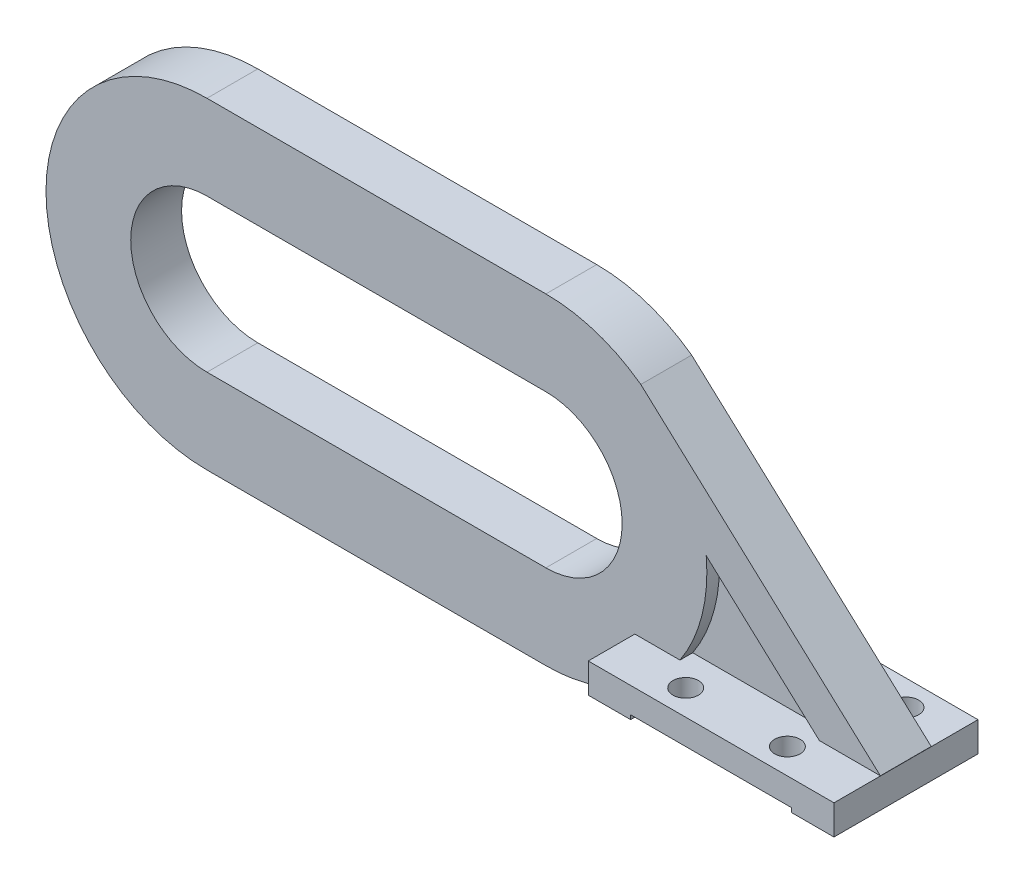
from build123d import *

# Parameters (mm, degrees)
SKETCH1_W           = 29
SKETCH1_H           = 17
SKETCH1_R           = 1.5
BOSS_EXTRUDE1_DEPTH = 3
SKETCH1_3_W         = 29
SKETCH1_3_H         = 17
SKETCH1_3_W_2       = 27
SKETCH1_3_H_2       = 15
BOSS_EXTRUDE2_DEPTH = 0.5
SKETCH3_W           = 19
SKETCH3_H           = 1
CUT_EXTRUDE1_DEPTH  = 6
BOSS_EXTRUDE3_DEPTH = 3
BOSS_EXTRUDE4_DEPTH = 1.5


with BuildPart() as part:
    # Sketch1 → Boss-Extrude1 (new body)
    with BuildSketch(Plane(origin=(0, 0, 0), x_dir=(1, 0, 0), z_dir=(0, 1, 0))):
        Rectangle(SKETCH1_W, SKETCH1_H)
        with Locations((-6, -5.5)):
            Circle(SKETCH1_R, mode=Mode.SUBTRACT)
        with Locations((6, -5.5)):
            Circle(SKETCH1_R, mode=Mode.SUBTRACT)
        with Locations((-9, 5.5)):
            Circle(SKETCH1_R, mode=Mode.SUBTRACT)
        with Locations((9, 5.5)):
            Circle(SKETCH1_R, mode=Mode.SUBTRACT)
    extrude(amount=BOSS_EXTRUDE1_DEPTH)

    # Sketch1_3 → Boss-Extrude2 (add)
    with BuildSketch(Plane(origin=(0, 0, 0), x_dir=(1, 0, 0), z_dir=(0, 1, 0))):
        Rectangle(SKETCH1_3_W, SKETCH1_3_H)
        Rectangle(SKETCH1_3_W_2, SKETCH1_3_H_2, mode=Mode.SUBTRACT)
    extrude(amount=-BOSS_EXTRUDE2_DEPTH)

    # Sketch3 → Cut-Extrude1 (cut)
    with BuildSketch(Plane.XY.offset(8.5)):
        with Locations((0, -0.5)):
            Rectangle(SKETCH3_W, SKETCH3_H)
    extrude(amount=-CUT_EXTRUDE1_DEPTH, mode=Mode.SUBTRACT)

    # Sketch4 → Boss-Extrude3 (add, symmetric)
    with BuildSketch(Plane.XY):
        with BuildLine():
            Line((-65, -5.482953492), (-25, -5.482953492))
            ThreePointArc((-25, -5.482953492), (-19.516691912, -4.674526607), (-14.5, -2.318041114))
            Line((-14.5, -2.318041114), (-14.5, 3))
            Line((-14.5, 3), (-9.176228871, 3))
            ThreePointArc((-9.176228871, 3), (-6.583274937, 8.845404617), (-6.076469935, 15.219988049))
            Line((-6.076469935, 15.219988049), (7.282732748, 3))
            Line((7.282732748, 3), (14.476431663, 3))
            Line((14.476431663, 3), (-13.79929628, 28.864496986))
            ThreePointArc((-13.79929628, 28.864496986), (-19.109395578, 31.580843992), (-25, 32.517046508))
            Line((-25, 32.517046508), (-65, 32.517046508))
            ThreePointArc((-65, 32.517046508), (-84, 13.517046508), (-65, -5.482953492))
        make_face()
        with BuildLine():
            ThreePointArc((-25, 22.517046508), (-16, 13.517046508), (-25, 4.517046508))
            Line((-25, 4.517046508), (-65, 4.517046508))
            ThreePointArc((-65, 4.517046508), (-74, 13.517046508), (-65, 22.517046508))
            Line((-65, 22.517046508), (-25, 22.517046508))
        make_face(mode=Mode.SUBTRACT)
    extrude(amount=BOSS_EXTRUDE3_DEPTH, both=True)

    # Sketch4_3 → Boss-Extrude4 (add, symmetric)
    with BuildSketch(Plane.XY):
        with BuildLine():
            ThreePointArc((-6.076469935, 15.219988049), (-6.583274937, 8.845404617), (-9.176228871, 3))
            Line((-9.176228871, 3), (7.282732748, 3))
            Line((7.282732748, 3), (-6.076469935, 15.219988049))
        make_face()
    extrude(amount=BOSS_EXTRUDE4_DEPTH, both=True)


solid = part.part
